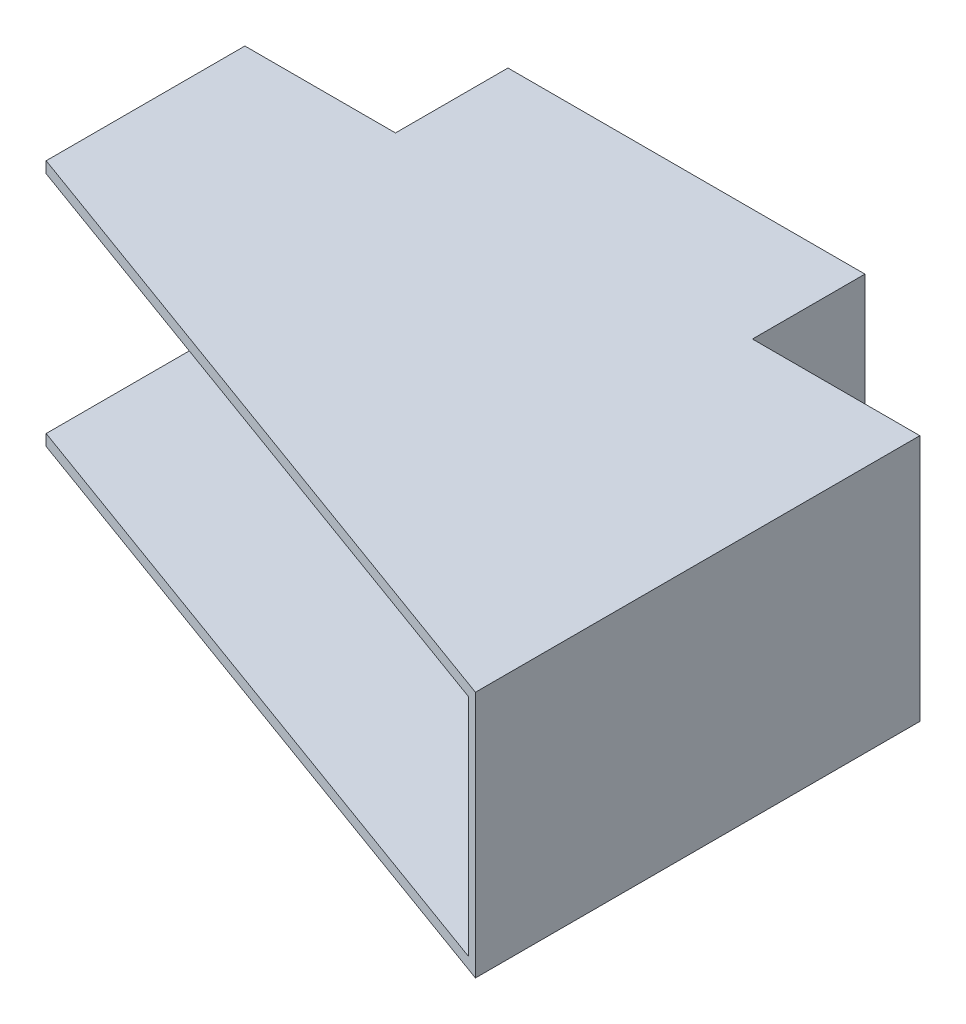
from build123d import *

# Parameters (mm, degrees)
SKETCH_1_W          = 180
SKETCH_1_H          = 66
EXTRUDE_1_DEPTH     = 3
SKETCH_2_W          = 180
SKETCH_2_H          = 3
EXTRUDE_2_DEPTH     = 50
SKETCH_3_W          = 9
SKETCH_3_H          = 32
EXTRUDE_3_DEPTH     = 30
SKETCH_4_W          = 22
SKETCH_4_H          = 5
SKETCH_4_H_2        = 4.5
EXTRUDE_4_DEPTH     = 12
SKETCH_9_W          = 180
SKETCH_9_H          = 66
EXTRUDE_7_DEPTH     = 30
EXTRUDE_8_DEPTH     = 66
EXTRUDE_9_DEPTH     = 3
EXTRUDE_10_DEPTH    = 3
EXTRUDE_11_DEPTH    = 60
SKETCH_16_R         = 1
CUT_EXTRUDE_1_DEPTH = 15
SKETCH_17_W         = 40.157277222
SKETCH_17_H         = 30
SKETCH_17_W_2       = 44.638770814
CUT_EXTRUDE_2_DEPTH = 67


with BuildPart() as part:
    # 草圖1 → 填料-伸長1 (new body)
    with BuildSketch(Plane.XY):
        with Locations((90, 33)):
            Rectangle(SKETCH_1_W, SKETCH_1_H)
    extrude(amount=EXTRUDE_1_DEPTH)

    # 草圖2 → 填料-伸長2 (add)
    with BuildSketch(Plane.XY.offset(3)):
        with Locations((90, 1.5)):
            Rectangle(SKETCH_2_W, SKETCH_2_H)
        with Locations((90, 64.5)):
            Rectangle(SKETCH_2_W, SKETCH_2_H)
    extrude(amount=EXTRUDE_2_DEPTH)

    # 草圖3 → 填料-伸長3 (add)
    with BuildSketch(Plane.ZY):
        with Locations((4.5, -16)):
            Rectangle(SKETCH_3_W, SKETCH_3_H)
    extrude(amount=-EXTRUDE_3_DEPTH)

    # 草圖4 → 填料-伸長4 (add)
    with BuildSketch(Plane.XY.offset(9)):
        with Locations((19, -2.5)):
            Rectangle(SKETCH_4_W, SKETCH_4_H)
        with Locations((19, -29.75)):
            Rectangle(SKETCH_4_W, SKETCH_4_H_2)
    extrude(amount=EXTRUDE_4_DEPTH)

    # 草圖9 → 填料-伸長7 (add)
    with BuildSketch(Plane(origin=(0, 0, 0), x_dir=(-1, 0, 0), z_dir=(0, 0, -1))):
        with Locations((-90, 33)):
            Rectangle(SKETCH_9_W, SKETCH_9_H)
    extrude(amount=EXTRUDE_7_DEPTH)

    # 草圖10 → 填料-伸長8 (add)
    with BuildSketch(Plane.XZ):
        Polygon((0, 0), (180, 0), (180, 68.514642168), (0, 3), align=None)
    extrude(amount=-EXTRUDE_8_DEPTH)

    # 草圖11 → 填料-伸長9 (add)
    with BuildSketch(Plane.XZ):
        Polygon((180, 68.514642168), (180, 118.514642168), (0, 53), (137.373870973, 53), align=None)
    extrude(amount=-EXTRUDE_9_DEPTH)

    # 草圖12 → 填料-伸長10 (add)
    with BuildSketch(Plane(origin=(0, 66, 0), x_dir=(1, 0, 0), z_dir=(0, 1, 0))):
        Polygon((180, -68.514642168), (180, -118.514642168), (0, -53), (137.373870973, -53), align=None)
    extrude(amount=-EXTRUDE_10_DEPTH)

    # 草圖14 → 填料-伸長11 (add)
    with BuildSketch(Plane.XZ.offset(-63)):
        Polygon((180, 118.514642168), (180, 68.514642168), (177.180922138, 67.488581738), (177.180922138, 117.488581738), align=None)
    extrude(amount=EXTRUDE_11_DEPTH)

    # 草圖16 → 除料-伸長1 (cut)
    with BuildSketch(Plane.ZY.offset(-8)):
        with Locations((15, -2.5)):
            Circle(SKETCH_16_R)
        with Locations((15, -30)):
            Circle(SKETCH_16_R)
    extrude(amount=-CUT_EXTRUDE_1_DEPTH, mode=Mode.SUBTRACT)

    # 草圖17 → 除料-伸長2 (cut, through all)
    with BuildSketch(Plane.XZ):
        with Locations((20.078638611, -15)):
            Rectangle(SKETCH_17_W, SKETCH_17_H)
        with Locations((157.680614593, -15)):
            Rectangle(SKETCH_17_W_2, SKETCH_17_H)
    extrude(amount=-CUT_EXTRUDE_2_DEPTH, mode=Mode.SUBTRACT)


solid = part.part
